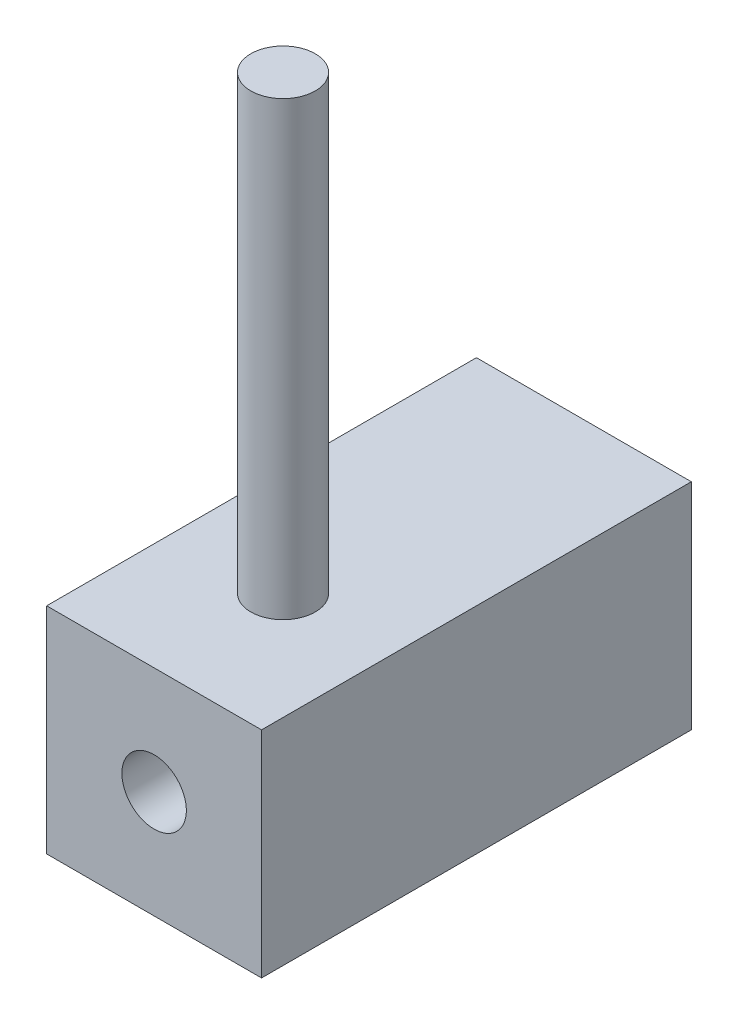
from build123d import *

# Parameters (mm, degrees)
SKETCH1_W           = 10
SKETCH1_H           = 20
BOSS_EXTRUDE1_DEPTH = 10
SKETCH3_R           = 1.5
CUT_EXTRUDE1_DEPTH  = 21
SKETCH2_R           = 1.5
BOSS_EXTRUDE2_DEPTH = 21


with BuildPart() as part:
    # Sketch1 → Boss-Extrude1 (new body)
    with BuildSketch(Plane(origin=(0, 0, 0), x_dir=(1, 0, 0), z_dir=(0, 1, 0))):
        with Locations((0.028248588, -7.485875706)):
            Rectangle(SKETCH1_W, SKETCH1_H)
    extrude(amount=BOSS_EXTRUDE1_DEPTH)

    # Sketch3 → Cut-Extrude1 (cut)
    with BuildSketch(Plane(origin=(0, 0, -2.514124294), x_dir=(-1, 0, 0), z_dir=(0, 0, -1))):
        with Locations((-0.028248588, 5)):
            Circle(SKETCH3_R)
    extrude(amount=-CUT_EXTRUDE1_DEPTH, mode=Mode.SUBTRACT)

    # Sketch2 → Boss-Extrude2 (add)
    with BuildSketch(Plane(origin=(0, 10, 0), x_dir=(1, 0, 0), z_dir=(0, 1, 0))):
        with Locations((0.028248588, -11.485875706)):
            Circle(SKETCH2_R)
    extrude(amount=BOSS_EXTRUDE2_DEPTH)


solid = part.part
